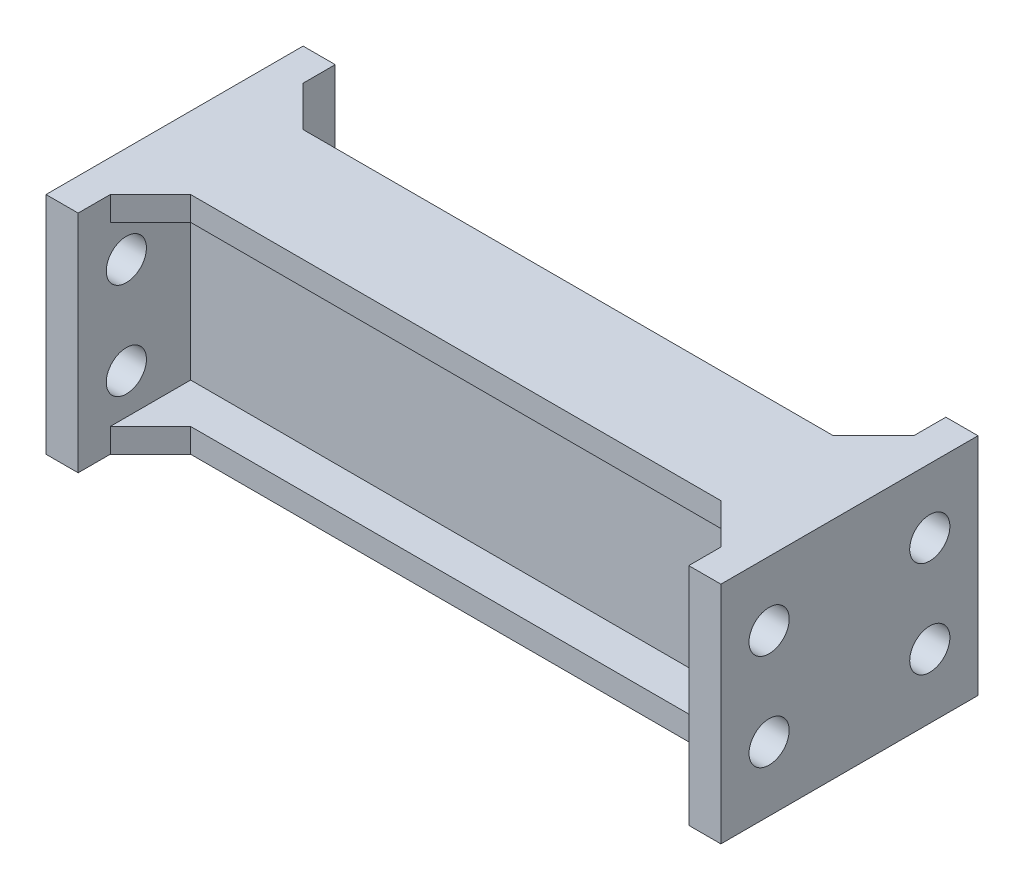
from build123d import *

# Parameters (mm, degrees)
BOSS_EXTRUDE1_DEPTH = 14
SKETCH2_R           = 1.25
CUT_EXTRUDE1_DEPTH  = 43
BOSS_EXTRUDE2_DEPTH = 1.5


with BuildPart() as part:
    # Sketch1 → Boss-Extrude1 (new body)
    with BuildSketch(Plane(origin=(0, 0, 0), x_dir=(1, 0, 0), z_dir=(0, 1, 0))):
        Polygon((-19, 1), (19, 1), (19, 8), (21, 8), (21, 1), (21, -1), (21, -8), (19, -8), (19, -1), (-19, -1), (-19, -8), (-21, -8), (-21, -1), (-21, 1), (-21, 8), (-19, 8), align=None)
    extrude(amount=BOSS_EXTRUDE1_DEPTH)

    # Sketch2 → Cut-Extrude1 (cut, through all)
    with BuildSketch(Plane(origin=(21, 0, 0), x_dir=(0, 0, -1), z_dir=(1, 0, 0))):
        with Locations((5, 10)):
            Circle(SKETCH2_R)
        with Locations((5, 4)):
            Circle(SKETCH2_R)
        with Locations((-5, 4)):
            Circle(SKETCH2_R)
        with Locations((-5, 10)):
            Circle(SKETCH2_R)
    extrude(amount=-CUT_EXTRUDE1_DEPTH, mode=Mode.SUBTRACT)

    # Sketch3 → Boss-Extrude2 (add)
    with BuildSketch(Plane(origin=(0, 14, 0), x_dir=(1, 0, 0), z_dir=(0, 1, 0))):
        Polygon((-19, 1), (-19, 6), (-16.5, 3.5), (16.5, 3.5), (19, 6), (19, 1), (14, 1), (-14, 1), align=None)
        Polygon((19, -1), (14, -1), (-14, -1), (-19, -1), (-19, -6), (-16.5, -3.5), (16.5, -3.5), (19, -6), align=None)
    boss_extrude2 = extrude(amount=-BOSS_EXTRUDE2_DEPTH)

    # Mirror1: Boss-Extrude2 across plane
    add(boss_extrude2.mirror(Plane.ZX.offset(7)))


solid = part.part
